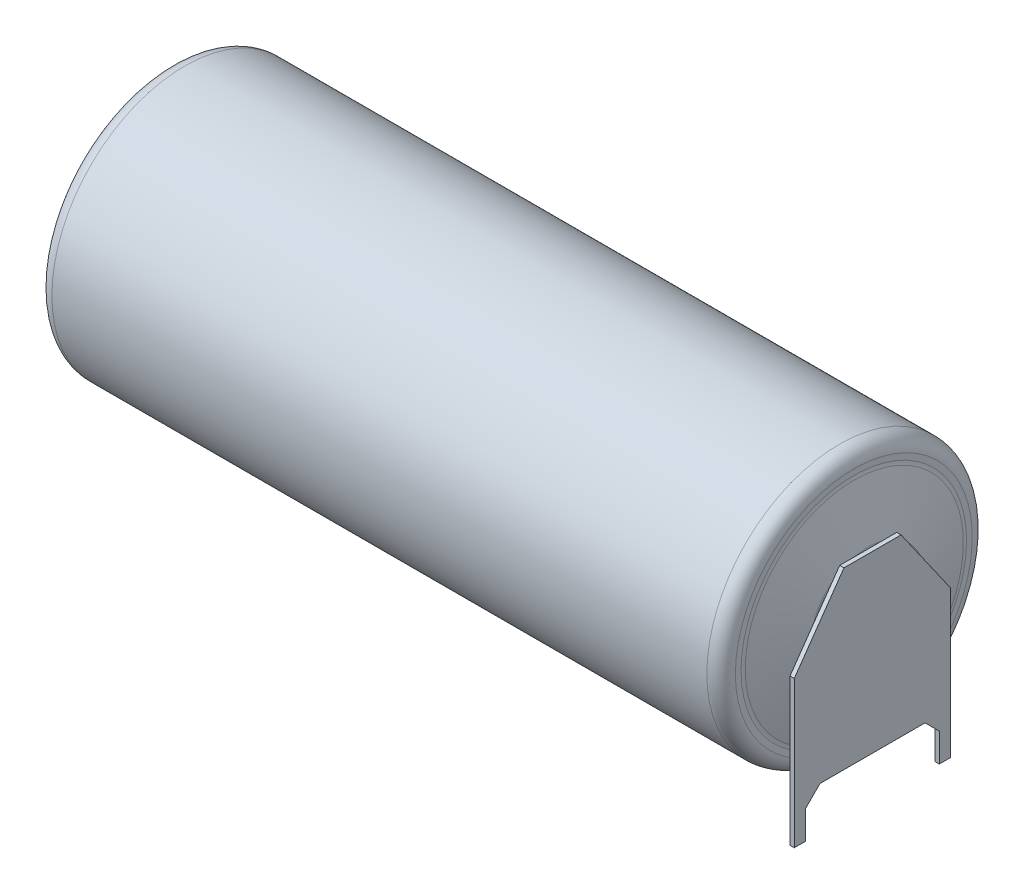
from build123d import *

# Parameters (mm, degrees)
BOSS_EXTRUDE1_DEPTH = 0.3
BOSS_EXTRUDE2_DEPTH = 0.3


with BuildPart() as part:
    # Sketch1 → Revolve1 (revolve)
    with BuildSketch(Plane.XY):
        with BuildLine():
            Line((-25.25, 0), (24.45, 0))
            Line((24.45, 0), (24.45, 0.7))
            ThreePointArc((24.45, 0.7), (24.479289322, 0.770710678), (24.55, 0.8))
            Line((24.55, 0.8), (25.15, 0.8))
            ThreePointArc((25.15, 0.8), (25.220710678, 0.829289322), (25.25, 0.9))
            Line((25.25, 0.9), (25.25, 3.947339001))
            ThreePointArc((25.25, 3.947339001), (25.246577945, 3.999549478), (25.236370331, 4.050866619))
            Line((25.236370331, 4.050866619), (24.274348504, 7.641180955))
            ThreePointArc((24.274348504, 7.641180955), (24.248829469, 7.769473808), (24.24027433, 7.9))
            Line((24.24027433, 7.9), (24.24027433, 8.3))
            ThreePointArc((24.24027433, 8.3), (23.947381111, 9.007106781), (23.24027433, 9.3))
            Line((23.24027433, 9.3), (-22.65, 9.3))
            ThreePointArc((-22.65, 9.3), (-23.357106781, 9.007106781), (-23.65, 8.3))
            Line((-23.65, 8.3), (-23.65, 7.4))
            ThreePointArc((-23.65, 7.4), (-23.620710678, 7.329289322), (-23.55, 7.3))
            Line((-23.55, 7.3), (-23.25, 7.3))
            ThreePointArc((-23.25, 7.3), (-23.179289322, 7.270710678), (-23.15, 7.2))
            Line((-23.15, 7.2), (-23.15, 4.35))
            ThreePointArc((-23.15, 4.35), (-23.179289322, 4.279289322), (-23.25, 4.25))
            Line((-23.25, 4.25), (-23.35, 4.25))
            ThreePointArc((-23.35, 4.25), (-23.420710678, 4.220710678), (-23.45, 4.15))
            Line((-23.45, 4.15), (-23.45, 2.9))
            ThreePointArc((-23.45, 2.9), (-23.567157288, 2.617157288), (-23.85, 2.5))
            Line((-23.85, 2.5), (-24.85, 2.5))
            ThreePointArc((-24.85, 2.5), (-25.132842712, 2.382842712), (-25.25, 2.1))
            Line((-25.25, 2.1), (-25.25, 0))
        make_face()
    revolve(axis=Axis((-25.25, 0, 0), (1, 0, 0)))

    # Sketch2 → Boss-Extrude1 (add)
    with BuildSketch(Plane(origin=(25.25, 0, 0), x_dir=(0, 0, -1), z_dir=(1, 0, 0))):
        Polygon((-2, 3.947339001), (2, 3.947339001), (5.48, -1.022616062), (5.48, -11.3), (4.68, -11.3), (4.68, -9.3), (3.68, -8.3), (-3.68, -8.3), (-4.68, -9.3), (-4.68, -11.3), (-5.48, -11.3), (-5.48, -1.022616062), align=None)
    extrude(amount=BOSS_EXTRUDE1_DEPTH)

    # Sketch3 → Boss-Extrude2 (add)
    with BuildSketch(Plane.ZY.offset(25.25)):
        Polygon((-1.75, 3), (1.75, 3), (1.75, -7.8), (0.4, -8.8), (0.4, -11.3), (-0.4, -11.3), (-0.4, -8.8), (-1.75, -7.8), align=None)
    extrude(amount=BOSS_EXTRUDE2_DEPTH)


solid = part.part
